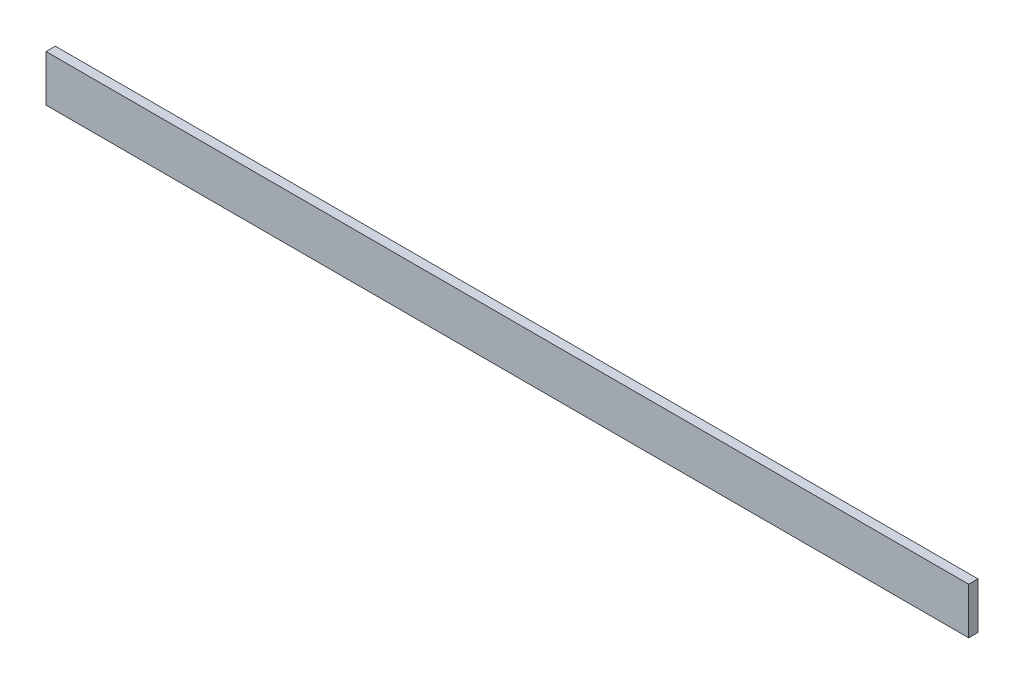
from build123d import *

# Parameters (mm, degrees)
ESQUISSE1_W      = 298
ESQUISSE1_H      = 15
EXTRUSION1_DEPTH = 1.5


with BuildPart() as part:
    # Esquisse1 → Extrusion1 (new body, symmetric)
    with BuildSketch(Plane.XY):
        Rectangle(ESQUISSE1_W, ESQUISSE1_H)
    extrude(amount=EXTRUSION1_DEPTH, both=True)


solid = part.part
